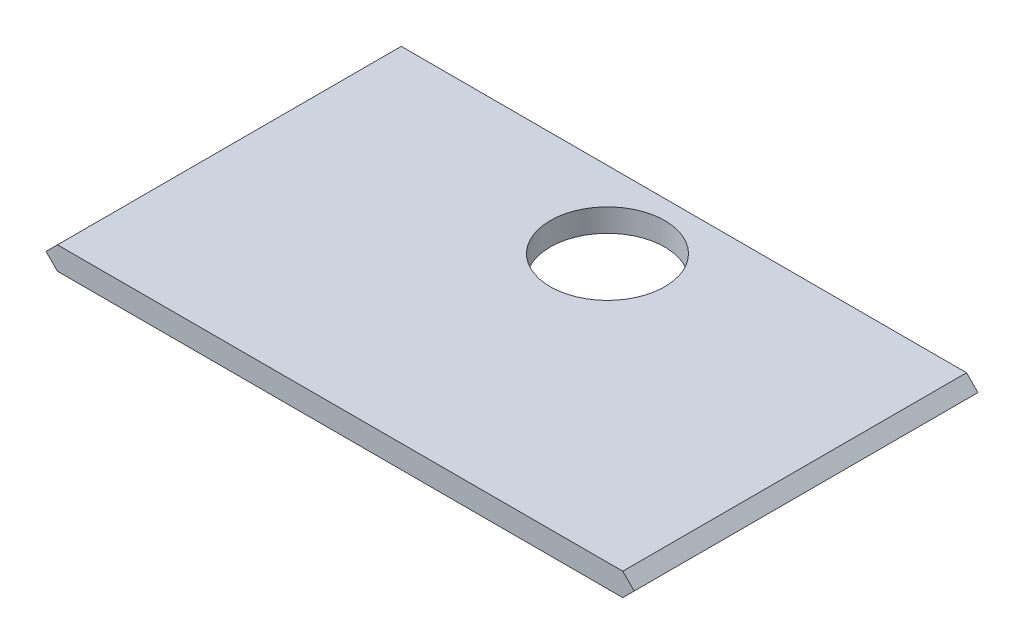
from build123d import *

# Parameters (mm, degrees)
BOSS_EXTRU_1_DEPTH      = 45
ESQUISSE2_R             = 7.5
ENL_V_MAT_EXTRU_1_DEPTH = 4


with BuildPart() as part:
    # Esquisse1 → Boss.-Extru.1 (new body)
    with BuildSketch(Plane.XY):
        Polygon((0, 0), (74, 0), (75.5, 1.5), (74, 3), (0, 3), (-1.5, 1.5), align=None)
    extrude(amount=BOSS_EXTRU_1_DEPTH)

    # Esquisse2 → Enlèv. mat.-Extru.1 (cut, through all)
    with BuildSketch(Plane(origin=(0, 3, 0), x_dir=(1, 0, 0), z_dir=(0, 1, 0))):
        with Locations((37, -10)):
            Circle(ESQUISSE2_R)
    extrude(amount=-ENL_V_MAT_EXTRU_1_DEPTH, mode=Mode.SUBTRACT)


solid = part.part
